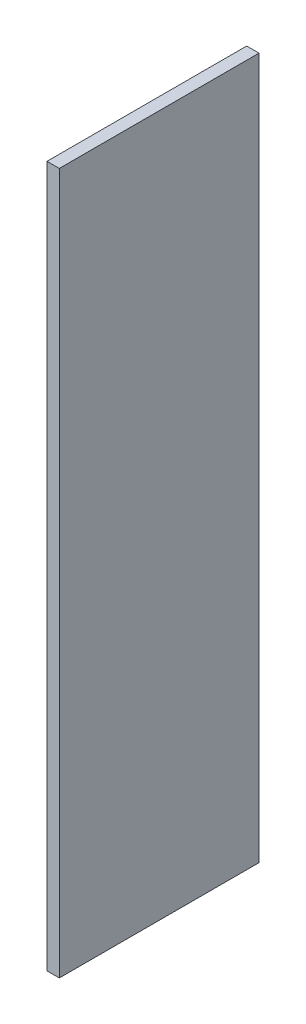
from build123d import *

# Parameters (mm, degrees)
SKETCH1_W           = 292
SKETCH1_H           = 1025
BOSS_EXTRUDE1_DEPTH = 18


with BuildPart() as part:
    # Sketch1 → Boss-Extrude1 (new body)
    with BuildSketch(Plane(origin=(0, 0, 0), x_dir=(0, 0, -1), z_dir=(1, 0, 0))):
        with Locations((-121.607933189, -454.719556499)):
            Rectangle(SKETCH1_W, SKETCH1_H)
    extrude(amount=BOSS_EXTRUDE1_DEPTH)


solid = part.part
